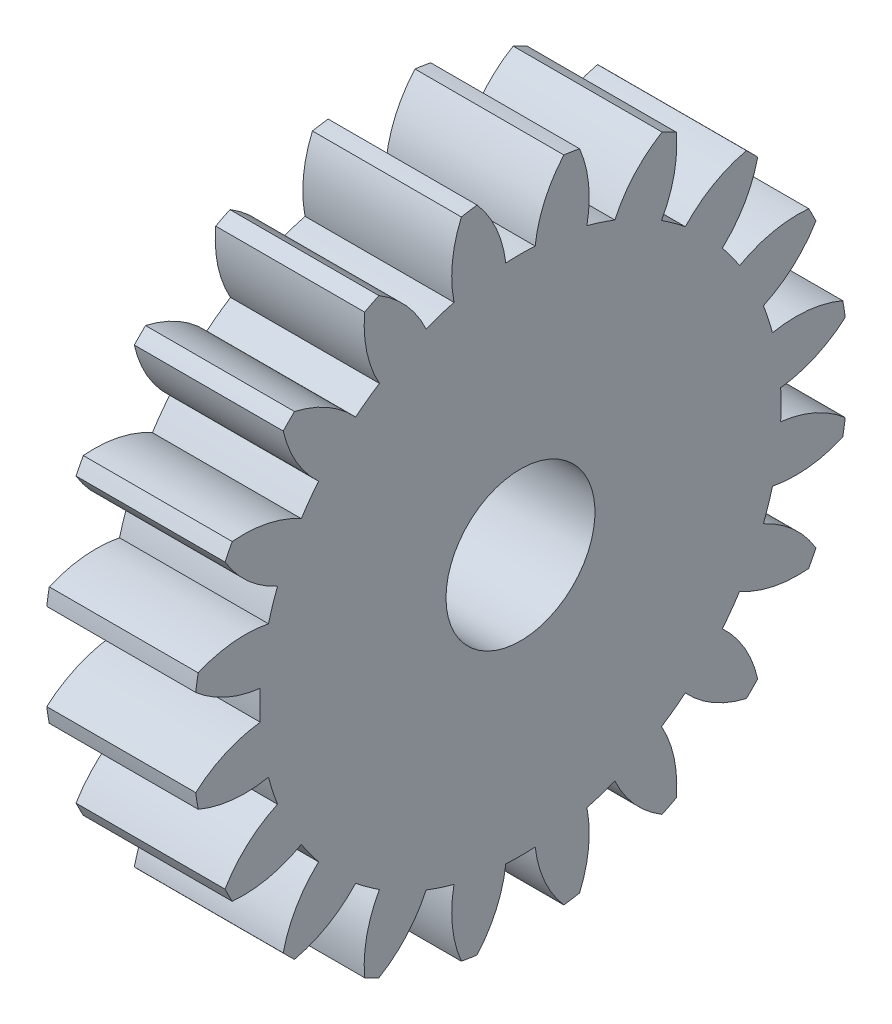
from build123d import *

# Parameters (mm, degrees)
BASPROSKE_W     = 10
BASPROSKE_H     = 22
TOOTHCUT_DEPTH  = 33.680269277
TEETHCUTS_COUNT = 20
TEETHCUTS_ANGLE = 342
BORSKE_R        = 5
BORE_DEPTH      = 50.0000508


with BuildPart() as part:
    # BasProSke → Base-Revolve (revolve)
    with BuildSketch(Plane(origin=(0, 0, 0), x_dir=(1, 0, 0), z_dir=(0, 1, 0)), mode=Mode.PRIVATE) as base_revolve_sk:
        with Locations((5, 11)):
            Rectangle(BASPROSKE_W, BASPROSKE_H)
    revolve(base_revolve_sk.sketch.rotate(Axis((-10, 0, 0), (1, 0, 0)), 180), axis=Axis((-10, 0, 0), (1, 0, 0)))

    # TooCutSke → ToothCut (cut, through all)
    with BuildSketch(Plane(origin=(0, 0, 0), x_dir=(0, 0, -1), z_dir=(1, 0, 0))):
        with BuildLine():
            ThreePointArc((0.986171591, 17.471189616), (0, 17.499), (-0.986171591, 17.471189616))
            ThreePointArc((-0.986171591, 17.471189616), (-1.626916196, 19.798789858), (-2.932850173, 21.829260982))
            ThreePointArc((-2.932850173, 21.829260982), (0, 22.0254), (2.932850173, 21.829260982))
            ThreePointArc((2.932850173, 21.829260982), (1.626916196, 19.798789858), (0.986171591, 17.471189616))
        make_face()
    toothcut = extrude(amount=TOOTHCUT_DEPTH, mode=Mode.SUBTRACT)

    # TeethCuts: ToothCut ×20 about axis
    teethcuts_axis = Axis((-10, 0, 0), (1, 0, 0))
    for i in range(1, TEETHCUTS_COUNT):
        add(toothcut.rotate(teethcuts_axis, i * TEETHCUTS_ANGLE / (TEETHCUTS_COUNT - 1)), mode=Mode.SUBTRACT)

    # BorSke → Bore (cut, symmetric)
    with BuildSketch(Plane(origin=(0, 0, 0), x_dir=(0, 0, -1), z_dir=(1, 0, 0))):
        with Locations(Location((0, 0, 0), (0, 0, 180))):
            Circle(BORSKE_R)
    extrude(amount=BORE_DEPTH, both=True, mode=Mode.SUBTRACT)


solid = part.part
